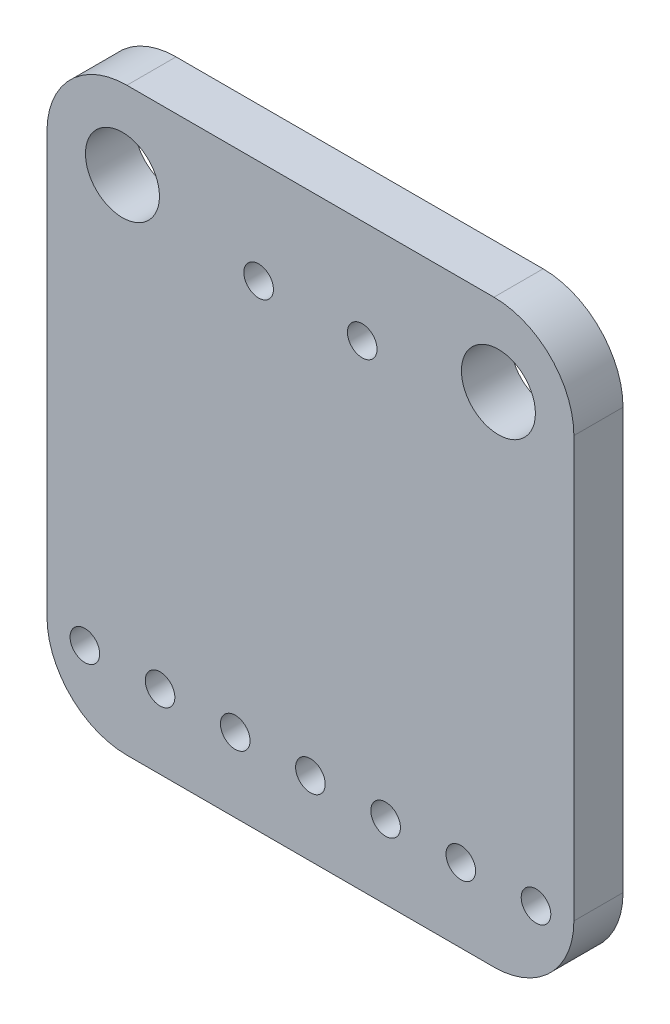
from build123d import *

# Parameters (mm, degrees)
SKETCH1_W                    = 17.8
SKETCH1_H                    = 19.6
BOSS_EXTRUDE1_DEPTH          = 1.66
FILLET1_R                    = 2.7
F_2_5_2_5_DIAMETER_HOLE1_D   = 2.5
F_1_0_1_DIAMETER_HOLE1_D     = 1
F_1_0_1_DIAMETER_HOLE1_DEPTH = 32
F_1_0_1_DIAMETER_HOLE1_TIP   = 0.30043031
LPATTERN1_COUNT              = 7
LPATTERN1_PITCH              = 2.54
SKETCH9_W                    = 3
SKETCH9_H                    = 3
BOSS_EXTRUDE2_DEPTH          = 1.2
SKETCH10_W                   = 2.5
SKETCH10_H                   = 1.25
SKETCH10_W_2                 = 1.25
SKETCH10_H_2                 = 2.5
BOSS_EXTRUDE3_DEPTH          = 1.2
SKETCH11_W                   = 2.4
SKETCH11_H                   = 1.3
BOSS_EXTRUDE4_DEPTH          = 0.5


with BuildPart() as part:
    # Sketch1 → Boss-Extrude1 (new body)
    with BuildSketch(Plane.XY):
        Rectangle(SKETCH1_W, SKETCH1_H)
    extrude(amount=BOSS_EXTRUDE1_DEPTH)

    # Fillet1
    fillet1_edges = [part.edges().sort_by_distance(p)[0] for p in [
        (-8.9, 9.8, 0.83),
        (8.9, 9.8, 0.83),
        (8.9, -9.8, 0.83),
        (-8.9, -9.8, 0.83),
    ]]
    fillet(fillet1_edges, radius=FILLET1_R)

    # Ø2.5 (2.5) Diameter Hole1 (through all)
    with Locations(Plane.XY.offset(1.66)):
        with Locations((-6.35, 7.1), (6.35, 7.1)):
            Hole(F_2_5_2_5_DIAMETER_HOLE1_D / 2)

    # Ø1.0 (1) Diameter Hole1
    with Locations(Plane(origin=(0, 0, 0), x_dir=(-1, 0, 0), z_dir=(0, 0, -1))):
        with Locations((-1.75, 6.3), (1.75, 6.3)):
            Hole(F_1_0_1_DIAMETER_HOLE1_D / 2, depth=F_1_0_1_DIAMETER_HOLE1_DEPTH)
            with Locations((0, 0, -(F_1_0_1_DIAMETER_HOLE1_DEPTH + F_1_0_1_DIAMETER_HOLE1_TIP / 2))):  # 118° drill point
                Cone(0, F_1_0_1_DIAMETER_HOLE1_D / 2, F_1_0_1_DIAMETER_HOLE1_TIP, mode=Mode.SUBTRACT)

    # Sketch7 → Ø1.0 (1) Diameter Hole2 (revolve, cut)
    with BuildSketch(Plane(origin=(7.62, -7.3, 0), x_dir=(0, 1, 0), z_dir=(1, 0, 0))):
        Polygon((0, 0), (0, 1.96043031), (0.5, 1.66), (0.5, 0), align=None)
    f_1_0_1_diameter_hole2 = revolve(axis=Axis((7.62, -7.3, -6.35), (0, 0, 1)), mode=Mode.SUBTRACT)

    # LPattern1: Ø1.0 (1) Diameter Hole2 ×7
    with Locations(*[(-i * LPATTERN1_PITCH, 0, 0) for i in range(1, LPATTERN1_COUNT)]):
        add(f_1_0_1_diameter_hole2, mode=Mode.SUBTRACT)

    # Sketch9 → Boss-Extrude2 (add)
    with BuildSketch(Plane(origin=(0, 0, 0), x_dir=(-1, 0, 0), z_dir=(0, 0, -1))):
        with Locations((0, -2)):
            Rectangle(SKETCH9_W, SKETCH9_H)
    extrude(amount=BOSS_EXTRUDE2_DEPTH)

    # Sketch10 → Boss-Extrude3 (add)
    with BuildSketch(Plane(origin=(0, 0, 0), x_dir=(-1, 0, 0), z_dir=(0, 0, -1))):
        with Locations((2.7, 1.5)):
            Rectangle(SKETCH10_W, SKETCH10_H)
        with Locations((-6.4, 1.5)):
            Rectangle(SKETCH10_W, SKETCH10_H)
        with Locations((-2.7, 1.5)):
            Rectangle(SKETCH10_W, SKETCH10_H)
        with Locations((6.4, 1.5)):
            Rectangle(SKETCH10_W, SKETCH10_H)
        with Locations((3.8, -1.5)):
            Rectangle(SKETCH10_W_2, SKETCH10_H_2)
        with Locations((6, -1.5)):
            Rectangle(SKETCH10_W_2, SKETCH10_H_2)
    extrude(amount=BOSS_EXTRUDE3_DEPTH)

    # Sketch11 → Boss-Extrude4 (add)
    with BuildSketch(Plane(origin=(0, 0, 0), x_dir=(-1, 0, 0), z_dir=(0, 0, -1))):
        with Locations((4.8, -4.35)):
            Rectangle(SKETCH11_W, SKETCH11_H)
    extrude(amount=BOSS_EXTRUDE4_DEPTH)


solid = part.part
